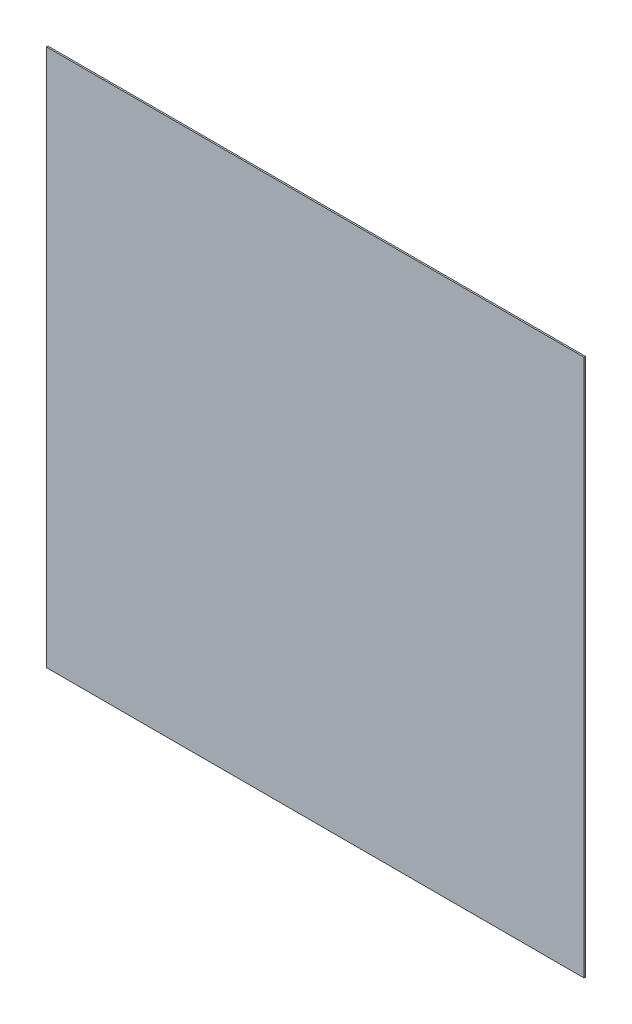
from build123d import *

# Parameters (mm, degrees)
SKETCH1_W           = 720
SKETCH1_H           = 720
BOSS_EXTRUDE1_DEPTH = 2
SKETCH2_R           = 5
BOSS_EXTRUDE2_DEPTH = 2


with BuildPart() as part:
    # Sketch1 → Boss-Extrude1 (new body)
    with BuildSketch(Plane.XY):
        Rectangle(SKETCH1_W, SKETCH1_H)
    extrude(amount=BOSS_EXTRUDE1_DEPTH)

    # Sketch2 → Boss-Extrude2 (add)
    with BuildSketch(Plane(origin=(0, 0, 0), x_dir=(-1, 0, 0), z_dir=(0, 0, -1))):
        with Locations((0, 340)):
            Circle(SKETCH2_R)
        with Locations((-340, 0)):
            Circle(SKETCH2_R)
        with Locations((0, -340)):
            Circle(SKETCH2_R)
        with Locations((340, 0)):
            Circle(SKETCH2_R)
    extrude(amount=BOSS_EXTRUDE2_DEPTH)


solid = part.part
